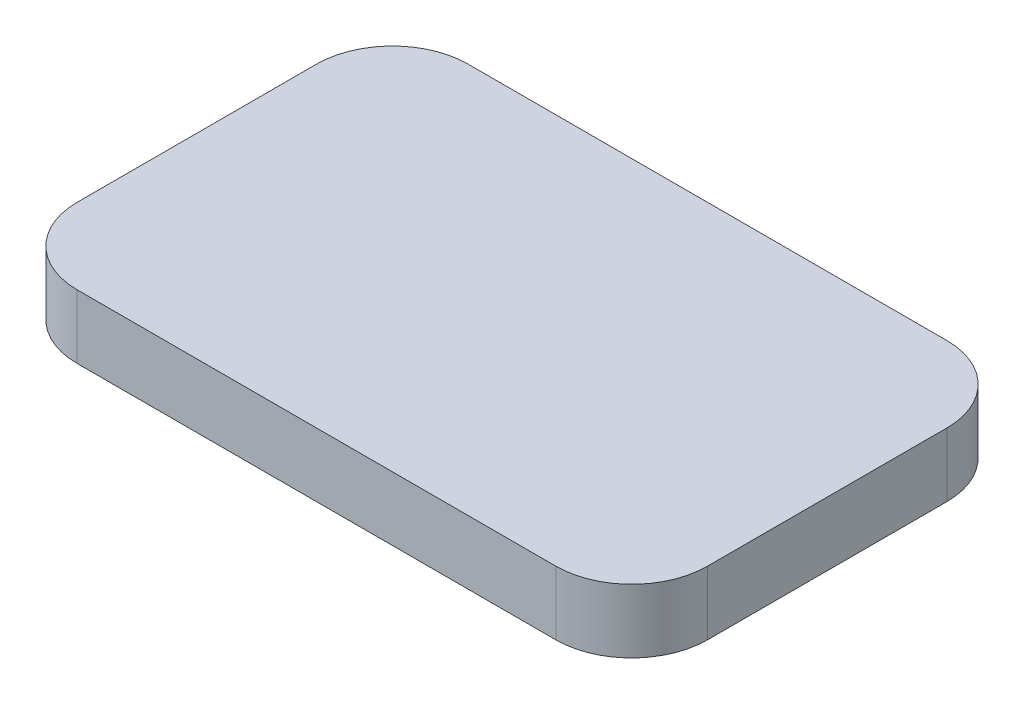
from build123d import *

# Parameters (mm, degrees)
SKETCH1_W           = 16
SKETCH1_H           = 16
BOSS_EXTRUDE1_DEPTH = 1.6
SKETCH2_OUTSIDE_W   = 22.536
SKETCH2_OUTSIDE_H   = 22.536
CUT_EXTRUDE1_DEPTH  = 1.6


with BuildPart() as part:
    # Sketch1 → Boss-Extrude1 (new body)
    with BuildSketch(Plane(origin=(0, 0, 0), x_dir=(1, 0, 0), z_dir=(0, 1, 0))):
        Rectangle(SKETCH1_W, SKETCH1_H)
    extrude(amount=BOSS_EXTRUDE1_DEPTH)

    # Sketch2 outside → Cut-Extrude1 (cut)
    with BuildSketch(Plane(origin=(0, 1.6, 0), x_dir=(1, 0, 0), z_dir=(0, 1, 0))):
        Rectangle(SKETCH2_OUTSIDE_W, SKETCH2_OUTSIDE_H)
        with BuildLine():
            Line((6.0045, 6.15), (-5.9955, 6.15))
            ThreePointArc((-5.9955, 6.15), (-7.339002884, 5.593502884), (-7.8955, 4.25))
            Line((-7.8955, 4.25), (-7.8955, -1.75))
            ThreePointArc((-7.8955, -1.75), (-7.339002884, -3.093502884), (-5.9955, -3.65))
            Line((-5.9955, -3.65), (6.0045, -3.65))
            ThreePointArc((6.0045, -3.65), (7.348002884, -3.093502884), (7.9045, -1.75))
            Line((7.9045, -1.75), (7.9045, 4.25))
            ThreePointArc((7.9045, 4.25), (7.348002884, 5.593502884), (6.0045, 6.15))
        make_face(mode=Mode.SUBTRACT)
    extrude(amount=-CUT_EXTRUDE1_DEPTH, mode=Mode.SUBTRACT)


solid = part.part
